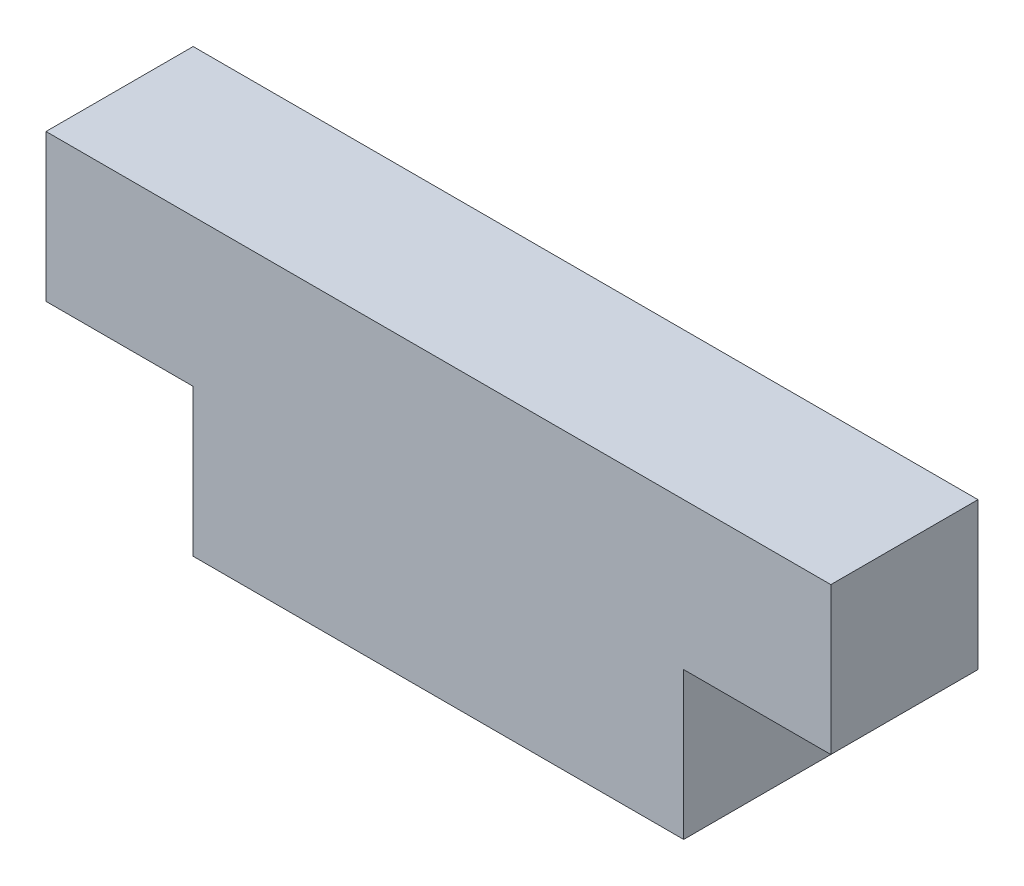
from build123d import *

# Parameters (mm, degrees)
CROQUIS1_W              = 10
CROQUIS1_H              = 3
SALIENTE_EXTRUIR1_DEPTH = 3
CROQUIS2_W              = 16
CROQUIS2_H              = 3
SALIENTE_EXTRUIR2_DEPTH = 3


with BuildPart() as part:
    # Croquis1 → Saliente-Extruir1 (new body)
    with BuildSketch(Plane(origin=(0, 0, 0), x_dir=(1, 0, 0), z_dir=(0, 1, 0))):
        Rectangle(CROQUIS1_W, CROQUIS1_H)
    extrude(amount=SALIENTE_EXTRUIR1_DEPTH)

    # Croquis2 → Saliente-Extruir2 (add)
    with BuildSketch(Plane(origin=(0, 3, 0), x_dir=(1, 0, 0), z_dir=(0, 1, 0))):
        Rectangle(CROQUIS2_W, CROQUIS2_H)
    extrude(amount=SALIENTE_EXTRUIR2_DEPTH)


solid = part.part
